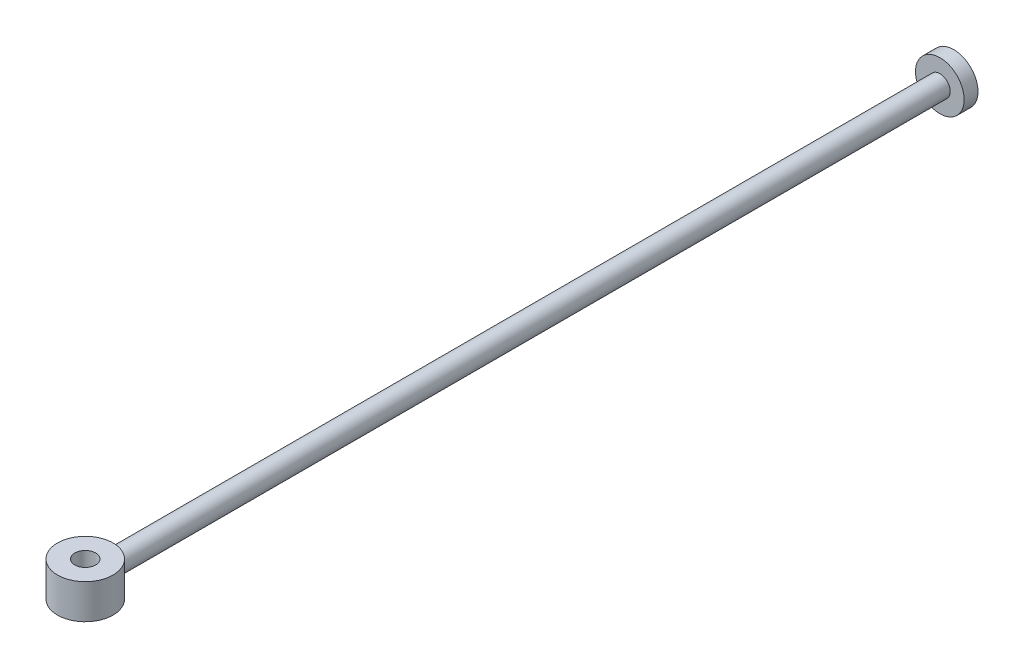
from build123d import *

# Parameters (mm, degrees)
SKETCH1_R                = 1.5
BOSS_EXTRUDE1_DEPTH      = 121
BOSS_EXTRUDE2_DEPTH      = 2.5
BOSS_EXTRUDE2_DEPTH_BACK = 2.5
SKETCH2_R                = 4
SKETCH2_R_2              = 1.5
SKETCH3_R                = 3.5
BOSS_EXTRUDE3_DEPTH      = 2


with BuildPart() as part:
    # Sketch1 → Boss-Extrude1 (new body)
    with BuildSketch(Plane.XY):
        Circle(SKETCH1_R)
    extrude(amount=BOSS_EXTRUDE1_DEPTH)

    # Sketch3 → Boss-Extrude3 (add)
    with BuildSketch(Plane(origin=(0, 0, 0), x_dir=(-1, 0, 0), z_dir=(0, 0, -1))):
        Circle(SKETCH3_R)
    extrude(amount=-BOSS_EXTRUDE3_DEPTH)


with BuildPart() as body_2:
    # Sketch2 → Boss-Extrude2 (new, two sides: drawn at the far end of the back side and taken through both)
    with BuildSketch(Plane(origin=(0, 0, 0), x_dir=(1, 0, 0), z_dir=(0, 1, 0)).offset(-BOSS_EXTRUDE2_DEPTH_BACK)):
        with Locations((0, -125)):
            Circle(SKETCH2_R)
        with Locations((0, -125)):
            Circle(SKETCH2_R_2, mode=Mode.SUBTRACT)
    extrude(amount=BOSS_EXTRUDE2_DEPTH + BOSS_EXTRUDE2_DEPTH_BACK)


solid = Compound([part.part, body_2.part])
